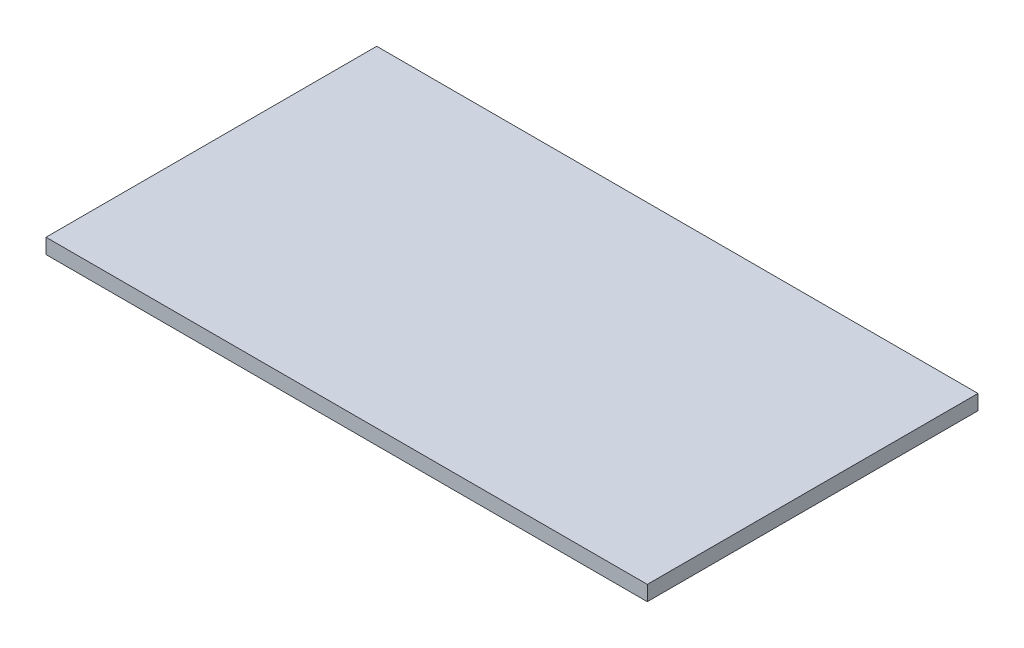
from build123d import *

# Parameters (mm, degrees)
ESQUISSE1_W        = 440
ESQUISSE1_H        = 20
BOSS_EXTRU_1_DEPTH = 800


with BuildPart() as part:
    # Esquisse1 → Boss.-Extru.1 (new body)
    with BuildSketch(Plane(origin=(0, 0, 0), x_dir=(0, 0, -1), z_dir=(1, 0, 0))):
        Rectangle(ESQUISSE1_W, ESQUISSE1_H)
    extrude(amount=BOSS_EXTRU_1_DEPTH)


solid = part.part
